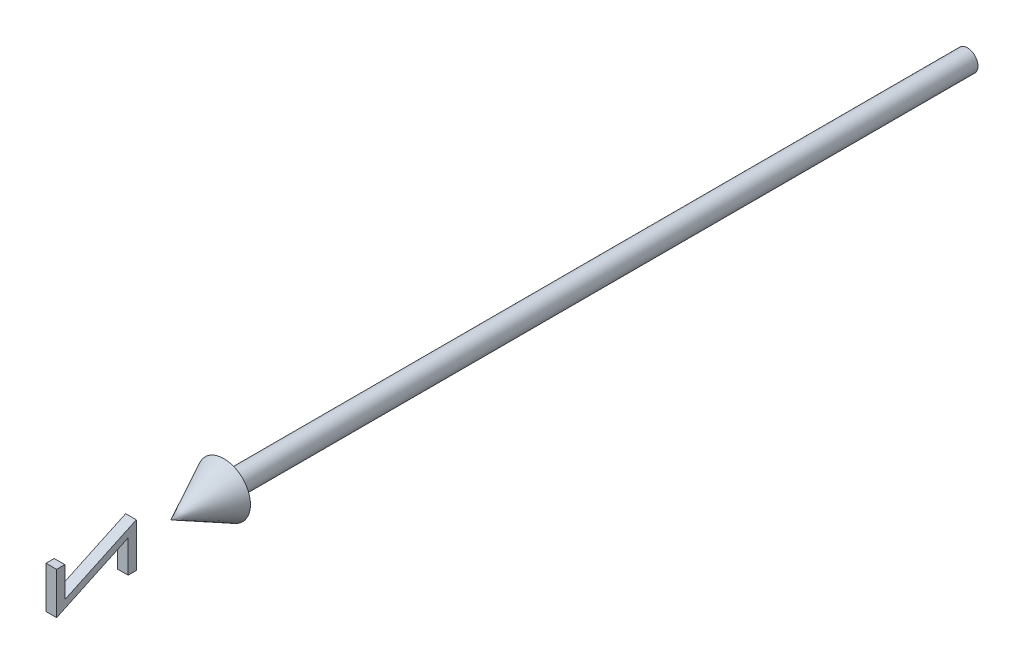
from build123d import *

# Parameters (mm, degrees)
BOSS_EXTRUDE1_DEPTH      = 1
BOSS_EXTRUDE1_DEPTH_BACK = 1


with BuildPart() as part:
    # Sketch2 → Revolve1 (revolve)
    with BuildSketch(Plane(origin=(0, 0, 0), x_dir=(1, 0, 0), z_dir=(0, 1, 0))):
        Polygon((0, -150), (5, -140), (2, -140), (2, 0), (0, 0), align=None)
    revolve(axis=Axis((0, 0, -41.949952025), (0, 0, 1)))


with BuildPart() as body_2:
    # Sketch3 → Boss-Extrude1 (new, two sides: drawn at the far end of the back side and taken through both)
    with BuildSketch(Plane(origin=(0, 0, 0), x_dir=(0, -1, 0), z_dir=(1, 0, 0)).offset(-BOSS_EXTRUDE1_DEPTH_BACK)):
        Polygon((-3.694719939, -170.961538462), (-3.694719939, -172.5), (4.189895446, -172.5), (-2.102171862, -159.038461538), (3.997587754, -159.038461538), (3.997587754, -157.5), (-4.271643016, -157.5), (2.020424292, -170.961538462), align=None)
    extrude(amount=BOSS_EXTRUDE1_DEPTH + BOSS_EXTRUDE1_DEPTH_BACK)


solid = Compound([part.part, body_2.part])
